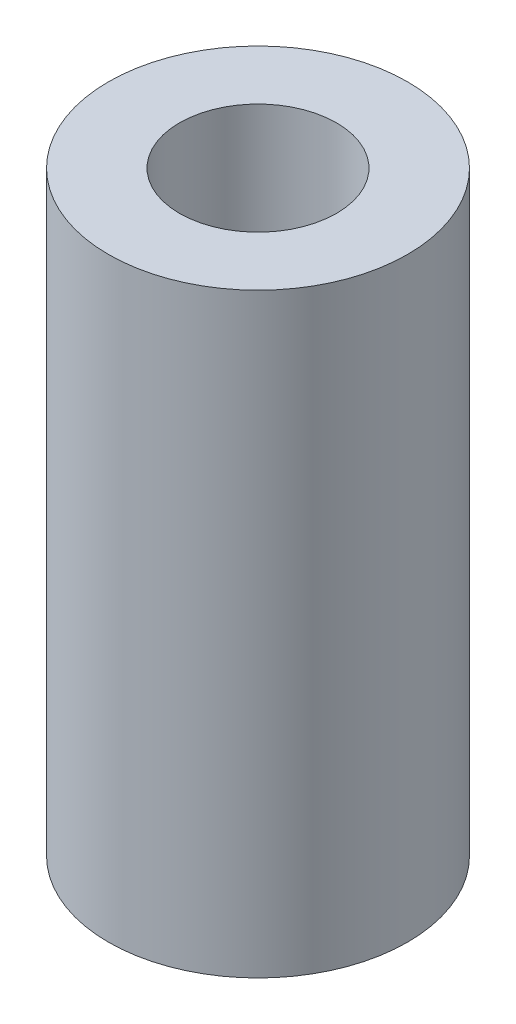
from build123d import *

# Parameters (mm, degrees)
SKETCH1_R           = 3.81
SKETCH1_R_2         = 2
BOSS_EXTRUDE1_DEPTH = 15.175


with BuildPart() as part:
    # Sketch1 → Boss-Extrude1 (new body)
    with BuildSketch(Plane(origin=(0, 0, 0), x_dir=(1, 0, 0), z_dir=(0, 1, 0))):
        Circle(SKETCH1_R)
        Circle(SKETCH1_R_2, mode=Mode.SUBTRACT)
    extrude(amount=BOSS_EXTRUDE1_DEPTH)


solid = part.part
